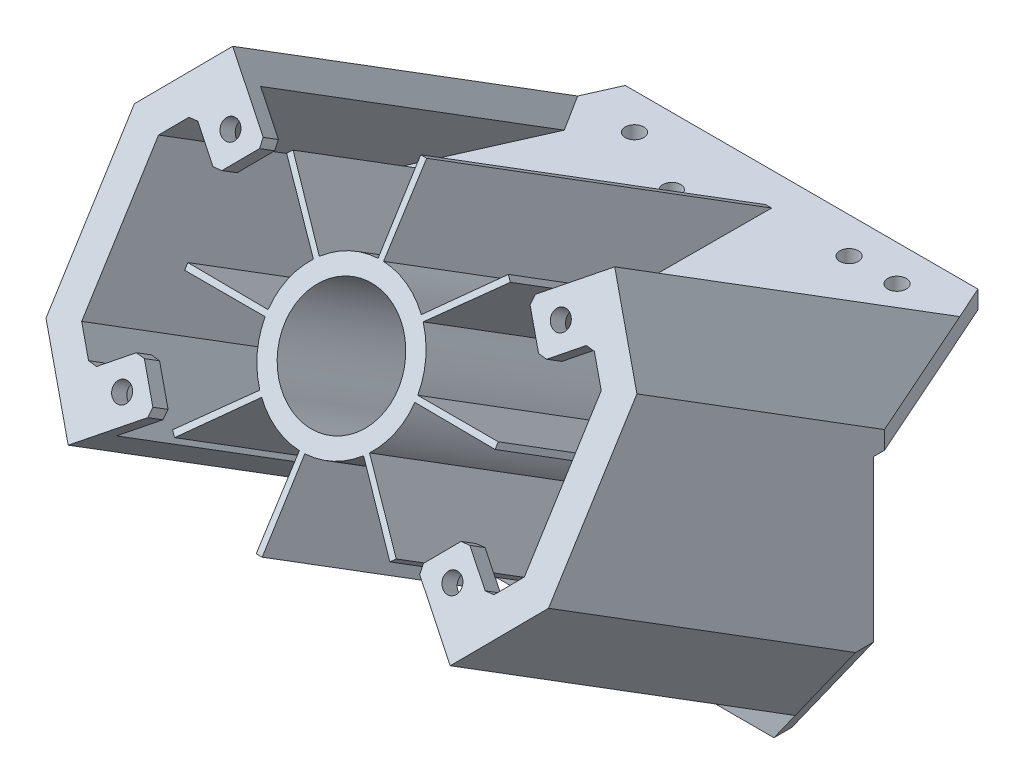
from build123d import *

# Parameters (mm, degrees)
BOSS_EXTRUDE1_DEPTH = 3
SKETCH3_W           = 84
SKETCH3_H           = 3
BOSS_EXTRUDE2_DEPTH = 30
BOSS_EXTRUDE3_DEPTH = 68
SKETCH8_R           = 9.5
BOSS_EXTRUDE4_DEPTH = 68
SKETCH9_W           = 30
SKETCH9_H           = 46
CUT_EXTRUDE3_DEPTH  = 85
CUT_EXTRUDE4_DEPTH  = 68
CUT_EXTRUDE5_DEPTH  = 68
BOSS_EXTRUDE5_DEPTH = 8
CHAMFER1_SIZE       = 1
BOSS_EXTRUDE6_DEPTH = 8
CHAMFER2_SIZE       = 1
BOSS_EXTRUDE7_DEPTH = 8
CHAMFER3_SIZE       = 1
BOSS_EXTRUDE8_DEPTH = 8
CHAMFER4_SIZE       = 1
CUT_EXTRUDE6_REACH  = 100.635
SKETCH17_R          = 1.55
CUT_EXTRUDE7_REACH  = 51
SKETCH18_R          = 1.55
SKETCH18_R_2        = 1.5
SKETCH21_W          = 45
SKETCH21_H          = 22
CUT_EXTRUDE8_DEPTH  = 58.667270539
SKETCH22_R          = 1.05
CUT_EXTRUDE9_DEPTH  = 3


with BuildPart() as part:
    # Sketch2 → Boss-Extrude1 (new body)
    with BuildSketch(Plane.XY):
        Polygon((-110, 46), (-110, 49), (-26, 49), (-26, 46), (-26, 0), (-110, 0), align=None)
    extrude(amount=BOSS_EXTRUDE1_DEPTH)

    # Sketch3 → Boss-Extrude2 (add)
    with BuildSketch(Plane(origin=(0, 0, 0), x_dir=(-1, 0, 0), z_dir=(0, 0, -1))):
        with Locations((68, 47.5)):
            Rectangle(SKETCH3_W, SKETCH3_H)
    extrude(amount=BOSS_EXTRUDE2_DEPTH)

    # Sketch7 → Boss-Extrude3 (add)
    with BuildSketch(Plane(origin=(0, 2.752263202, 4.404541836), x_dir=(1, 0, 0), z_dir=(0, 0.529919264, 0.848048096))):
        Polygon((-110, 14.650482688), (-99.930804426, 2.650482688), (-96.10058221, 5.864420737), (-105, 16.470333859), (-105, 40.714481265), (-96.10058221, 51.320394388), (-99.930804426, 54.534332436), (-110, 42.534332436), align=None)
        Polygon((-39.89941779, 5.864420737), (-36.069195574, 2.650482688), (-26, 14.650482688), (-26, 39.964598919), (-26, 42.534332436), (-36.069195574, 54.534332436), (-39.89941779, 51.320394388), (-31, 40.714481265), (-31, 16.470333859), align=None)
    extrude(amount=BOSS_EXTRUDE3_DEPTH)

    # Sketch8 → Boss-Extrude4 (add)
    with BuildSketch(Plane(origin=(0, 2.752263202, 4.404541836), x_dir=(1, 0, 0), z_dir=(0, 0.529919264, 0.848048096))):
        with BuildLine():
            Line((-67.5, 54.534332436), (-68.5, 54.534332436))
            Line((-68.5, 54.534332436), (-68.5, 41.082403559))
            ThreePointArc((-68.5, 41.082403559), (-72.822037178, 40.124881601), (-76.539295111, 37.720958324))
            Line((-76.539295111, 37.720958324), (-85.990157605, 47.289671948))
            Line((-85.990157605, 47.289671948), (-86.697264386, 46.582565167))
            Line((-86.697264386, 46.582565167), (-77.185314257, 37.070615038))
            ThreePointArc((-77.185314257, 37.070615038), (-79.564385784, 33.337402971), (-80.493053625, 29.009074229))
            Line((-80.493053625, 29.009074229), (-93.941924874, 29.092407562))
            Line((-93.941924874, 29.092407562), (-93.941924874, 28.092407562))
            Line((-93.941924874, 28.092407562), (-80.489995997, 28.092407562))
            ThreePointArc((-80.489995997, 28.092407562), (-79.532474039, 23.770370384), (-77.128550762, 20.053112451))
            Line((-77.128550762, 20.053112451), (-86.697264386, 10.602249957))
            Line((-86.697264386, 10.602249957), (-85.990157605, 9.895143176))
            Line((-85.990157605, 9.895143176), (-76.478207476, 19.407093305))
            ThreePointArc((-76.478207476, 19.407093305), (-72.744995409, 17.028021778), (-68.416666667, 16.099353937))
            Line((-68.416666667, 16.099353937), (-68.5, 2.650482688))
            Line((-68.5, 2.650482688), (-67.5, 2.650482688))
            Line((-67.5, 2.650482688), (-67.5, 16.102411565))
            ThreePointArc((-67.5, 16.102411565), (-63.177962822, 17.059933523), (-59.460704889, 19.4638568))
            Line((-59.460704889, 19.4638568), (-50.009842395, 9.895143176))
            Line((-50.009842395, 9.895143176), (-49.302735614, 10.602249957))
            Line((-49.302735614, 10.602249957), (-58.814685743, 20.114200086))
            ThreePointArc((-58.814685743, 20.114200086), (-56.435614216, 23.847412153), (-55.506946375, 28.175740895))
            Line((-55.506946375, 28.175740895), (-42.058075126, 28.092407562))
            Line((-42.058075126, 28.092407562), (-42.058075126, 29.092407562))
            Line((-42.058075126, 29.092407562), (-55.510004003, 29.092407562))
            ThreePointArc((-55.510004003, 29.092407562), (-56.467525961, 33.41444474), (-58.871449238, 37.131702673))
            Line((-58.871449238, 37.131702673), (-49.302735614, 46.582565167))
            Line((-49.302735614, 46.582565167), (-50.009842395, 47.289671948))
            Line((-50.009842395, 47.289671948), (-59.521792524, 37.777721819))
            ThreePointArc((-59.521792524, 37.777721819), (-63.255004591, 40.156793346), (-67.583333333, 41.085461188))
            Line((-67.583333333, 41.085461188), (-67.5, 54.534332436))
        make_face()
        with Locations((-68, 28.592407562)):
            Circle(SKETCH8_R, mode=Mode.SUBTRACT)
    extrude(amount=BOSS_EXTRUDE4_DEPTH)

    # Sketch9 → Cut-Extrude3 (cut, through all)
    with BuildSketch(Plane.ZY.offset(110)):
        with Locations((-15, 23)):
            Rectangle(SKETCH9_W, SKETCH9_H)
    extrude(amount=-CUT_EXTRUDE3_DEPTH, mode=Mode.SUBTRACT)

    # Sketch11 → Cut-Extrude4 (cut)
    with BuildSketch(Plane(origin=(0, 49, 0), x_dir=(1, 0, 0), z_dir=(0, 1, 0))):
        Polygon((-26, 1.849292506), (-36.069195574, 24.494251484), (-38.517354506, 30), (-26, 30), align=None)
        Polygon((-110, 1.849292506), (-99.930804426, 24.494251484), (-97.482645494, 30), (-110, 30), align=None)
    extrude(amount=-CUT_EXTRUDE4_DEPTH, mode=Mode.SUBTRACT)

    # Sketch12 → Cut-Extrude5 (cut)
    with BuildSketch(Plane.XY.offset(3)):
        Polygon((-110, 19.15014084), (-99.930804426, 5), (-96.372820202, 0), (-110, 0), align=None)
        Polygon((-26, 19.15014084), (-36.069195574, 5), (-39.627179798, 0), (-26, 0), align=None)
    extrude(amount=-CUT_EXTRUDE5_DEPTH, mode=Mode.SUBTRACT)

    # Sketch13 → Boss-Extrude5 (add)
    with BuildSketch(Plane(origin=(-81.664497732, 58.112198911, -36.312532071), x_dir=(0.277530914, -0.197490123, -0.940199045), z_dir=(0.766044443, -0.545114809, 0.340625537))):
        Polygon((-75.716604077, 11.344887623), (-73.010640587, 10.049603257), (-76.464732228, 2.833700616), (-79.170695719, 4.128984981), align=None)
    extrude(amount=BOSS_EXTRUDE5_DEPTH)

    # Chamfer1
    chamfer1_edges = [part.edges().sort_by_distance(p)[0] for p in [
        (-101.242883088, 76.316916776, 36.851608258),
        (-95.114527543, 71.955998307, 39.576612555),
        (-89.972226665, 77.153138559, 36.329078894),
    ]]
    chamfer(chamfer1_edges, length=CHAMFER1_SIZE)

    # Sketch14 → Boss-Extrude6 (add)
    with BuildSketch(Plane(origin=(-53.506473088, -38.075037421, 23.791923957), x_dir=(-0.277530914, -0.197490123, -0.940199045), z_dir=(0.766044443, 0.545114809, -0.340625537))):
        Polygon((-37.409332735, 91.372162271), (-34.703369245, 90.076877905), (-31.249277603, 97.292780547), (-33.955241094, 98.588064912), align=None)
    extrude(amount=BOSS_EXTRUDE6_DEPTH)

    # Chamfer2
    chamfer2_edges = [part.edges().sort_by_distance(p)[0] for p in [
        (-101.242883088, 48.162345367, 54.444537047),
        (-89.972226665, 47.326123584, 54.967066411),
        (-95.114527543, 52.523263836, 51.71953275),
    ]]
    chamfer(chamfer2_edges, length=CHAMFER2_SIZE)

    # Sketch15 → Boss-Extrude7 (add)
    with BuildSketch(Plane(origin=(1.856421651, 1.321023789, -0.825467279), x_dir=(0.277530914, 0.197490123, 0.940199045), z_dir=(-0.766044443, -0.545114809, 0.340625537))):
        Polygon((37.972399808, 90.195865404), (35.266436317, 88.900581038), (38.720527959, 81.684678396), (41.426491449, 82.979962762), align=None)
    extrude(amount=BOSS_EXTRUDE7_DEPTH)

    # Chamfer3
    chamfer3_edges = [part.edges().sort_by_distance(p)[0] for p in [
        (-34.757116912, 76.316916776, 36.851608258),
        (-46.027773335, 77.153138559, 36.329078894),
        (-40.885472457, 71.955998307, 39.576612555),
    ]]
    chamfer(chamfer3_edges, length=CHAMFER3_SIZE)

    # Sketch16 → Boss-Extrude8 (add)
    with BuildSketch(Plane(origin=(-26.301602994, 18.716137701, -11.695140835), x_dir=(-0.277530914, 0.197490123, 0.940199045), z_dir=(-0.766044443, 0.545114809, -0.340625537))):
        Polygon((75.153537005, 12.52118449), (72.447573514, 11.225900124), (68.993481872, 18.441802766), (71.699445363, 19.737087131), align=None)
    extrude(amount=BOSS_EXTRUDE8_DEPTH)

    # Chamfer4
    chamfer4_edges = [part.edges().sort_by_distance(p)[0] for p in [
        (-34.757116912, 48.162345367, 54.444537047),
        (-40.885472457, 52.523263836, 51.71953275),
        (-46.027773335, 47.326123584, 54.967066411),
    ]]
    chamfer(chamfer4_edges, length=CHAMFER4_SIZE)

    # Sketch17 → Cut-Extrude6 (cut, up to next)
    with BuildSketch(Plane(origin=(0, 38.78677317, 62.071812375), x_dir=(1, 0, 0), z_dir=(0, 0.529919264, 0.848048096)), mode=Mode.PRIVATE) as cut_extrude6_sk1:
        with Locations((-95.607554877, 45.685066176)):
            Circle(SKETCH17_R)
    cut_extrude6_tool1 = extrude(cut_extrude6_sk1.sketch, amount=-CUT_EXTRUDE6_REACH, mode=Mode.PRIVATE) & part.part
    add(cut_extrude6_tool1.solids().sort_by_distance((-95.607555, 77.529907, 37.862416))[0], mode=Mode.SUBTRACT)
    # Sketch17 → Cut-Extrude6 (cut, up to next)
    with BuildSketch(Plane(origin=(0, 38.78677317, 62.071812375), x_dir=(1, 0, 0), z_dir=(0, 0.529919264, 0.848048096)), mode=Mode.PRIVATE) as cut_extrude6_sk2:
        with Locations((-95.607554877, 11.499748948)):
            Circle(SKETCH17_R)
    cut_extrude6_tool2 = extrude(cut_extrude6_sk2.sketch, amount=-CUT_EXTRUDE6_REACH, mode=Mode.PRIVATE) & part.part
    add(cut_extrude6_tool2.solids().sort_by_distance((-95.607555, 48.539113, 55.977874))[0], mode=Mode.SUBTRACT)
    # Sketch17 → Cut-Extrude6 (cut, up to next)
    with BuildSketch(Plane(origin=(0, 38.78677317, 62.071812375), x_dir=(1, 0, 0), z_dir=(0, 0.529919264, 0.848048096)), mode=Mode.PRIVATE) as cut_extrude6_sk3:
        with Locations((-40.392445123, 45.685066176)):
            Circle(SKETCH17_R)
    cut_extrude6_tool3 = extrude(cut_extrude6_sk3.sketch, amount=-CUT_EXTRUDE6_REACH, mode=Mode.PRIVATE) & part.part
    add(cut_extrude6_tool3.solids().sort_by_distance((-40.392445, 77.529907, 37.862416))[0], mode=Mode.SUBTRACT)
    # Sketch17 → Cut-Extrude6 (cut, up to next)
    with BuildSketch(Plane(origin=(0, 38.78677317, 62.071812375), x_dir=(1, 0, 0), z_dir=(0, 0.529919264, 0.848048096)), mode=Mode.PRIVATE) as cut_extrude6_sk4:
        with Locations((-40.392445123, 11.499748948)):
            Circle(SKETCH17_R)
    cut_extrude6_tool4 = extrude(cut_extrude6_sk4.sketch, amount=-CUT_EXTRUDE6_REACH, mode=Mode.PRIVATE) & part.part
    add(cut_extrude6_tool4.solids().sort_by_distance((-40.392445, 48.539113, 55.977874))[0], mode=Mode.SUBTRACT)

    # Sketch18 → Cut-Extrude7 (cut, up to next)
    with BuildSketch(Plane(origin=(0, 49, 0), x_dir=(1, 0, 0), z_dir=(0, 1, 0)), mode=Mode.PRIVATE) as cut_extrude7_sk1:
        with Locations((-89.930804426, 24)):
            Circle(SKETCH18_R)
    cut_extrude7_tool1 = extrude(cut_extrude7_sk1.sketch, amount=-CUT_EXTRUDE7_REACH, mode=Mode.PRIVATE) & part.part
    add(cut_extrude7_tool1.solids().sort_by_distance((-89.930804, 49, -24))[0], mode=Mode.SUBTRACT)
    # Sketch18 → Cut-Extrude7 (cut, up to next)
    with BuildSketch(Plane(origin=(0, 49, 0), x_dir=(1, 0, 0), z_dir=(0, 1, 0)), mode=Mode.PRIVATE) as cut_extrude7_sk2:
        with Locations((-54.069195574, 24)):
            Circle(SKETCH18_R)
    cut_extrude7_tool2 = extrude(cut_extrude7_sk2.sketch, amount=-CUT_EXTRUDE7_REACH, mode=Mode.PRIVATE) & part.part
    add(cut_extrude7_tool2.solids().sort_by_distance((-54.069196, 49, -24))[0], mode=Mode.SUBTRACT)
    # Sketch18 → Cut-Extrude7 (cut, up to next)
    with BuildSketch(Plane(origin=(0, 49, 0), x_dir=(1, 0, 0), z_dir=(0, 1, 0)), mode=Mode.PRIVATE) as cut_extrude7_sk3:
        with Locations((-46.069195574, 24)):
            Circle(SKETCH18_R)
    cut_extrude7_tool3 = extrude(cut_extrude7_sk3.sketch, amount=-CUT_EXTRUDE7_REACH, mode=Mode.PRIVATE) & part.part
    add(cut_extrude7_tool3.solids().sort_by_distance((-46.069196, 49, -24))[0], mode=Mode.SUBTRACT)
    # Sketch18 → Cut-Extrude7 (cut, up to next)
    with BuildSketch(Plane(origin=(0, 49, 0), x_dir=(1, 0, 0), z_dir=(0, 1, 0)), mode=Mode.PRIVATE) as cut_extrude7_sk4:
        with Locations((-78.5, 18.8)):
            Circle(SKETCH18_R_2)
    cut_extrude7_tool4 = extrude(cut_extrude7_sk4.sketch, amount=-CUT_EXTRUDE7_REACH, mode=Mode.PRIVATE) & part.part
    add(cut_extrude7_tool4.solids().sort_by_distance((-78.5, 49, -18.8))[0], mode=Mode.SUBTRACT)

    # Sketch21 → Cut-Extrude8 (cut, through all)
    with BuildSketch(Plane.XY.offset(3)):
        with Locations((-68, 7.45)):
            Rectangle(SKETCH21_W, SKETCH21_H)
    extrude(amount=CUT_EXTRUDE8_DEPTH, mode=Mode.SUBTRACT)

    # Sketch22 → Cut-Extrude9 (cut)
    with BuildSketch(Plane.XY.offset(3)):
        with Locations((-48, -1.05)):
            Circle(SKETCH22_R)
        with Locations((-88, -1.05)):
            Circle(SKETCH22_R)
        with Locations((-88, 15.95)):
            Circle(SKETCH22_R)
        with Locations((-48, 15.95)):
            Circle(SKETCH22_R)
    extrude(amount=-CUT_EXTRUDE9_DEPTH, mode=Mode.SUBTRACT)


solid = part.part
